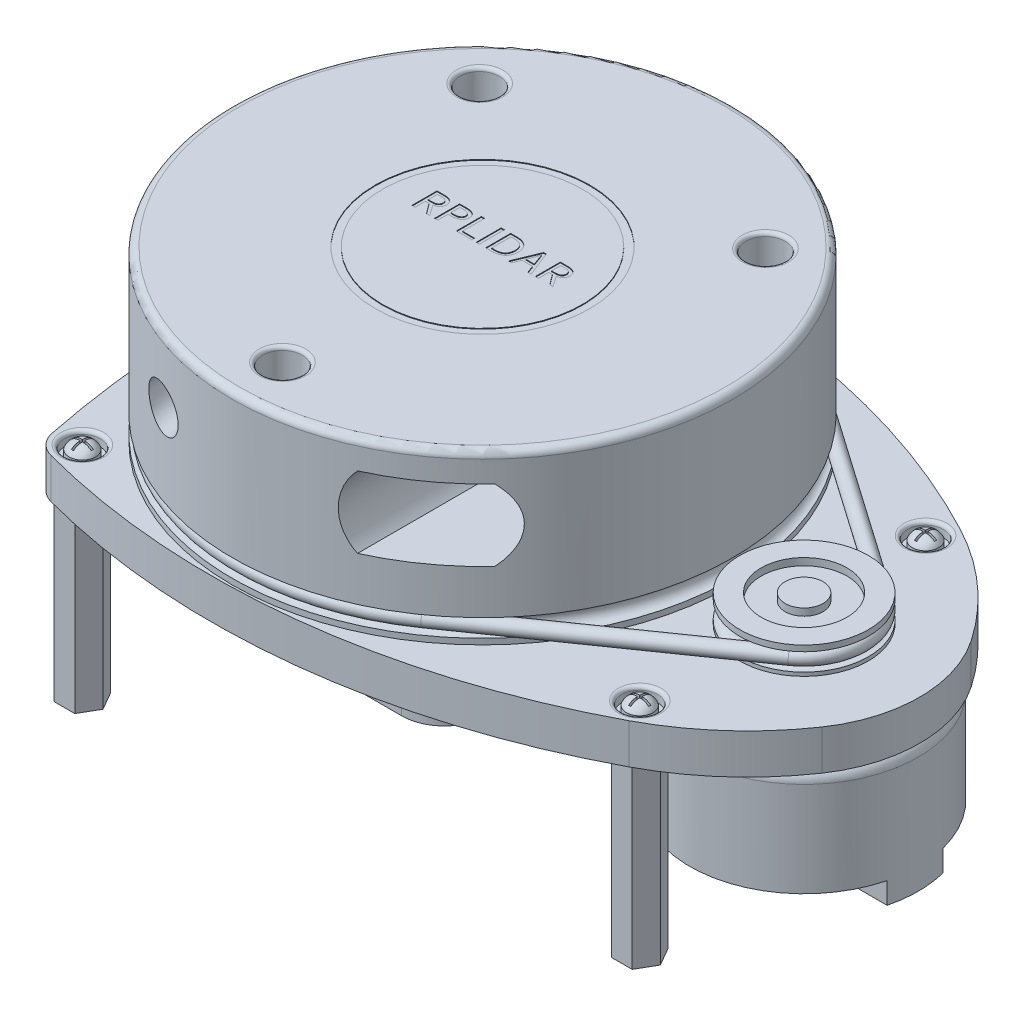
from build123d import *

# Parameters (mm, degrees)
SKETCH1_R                   = 35
PUCK_DEPTH                  = 23.5
FILLET1_R                   = 1
CUT_SENSOR_TUNNEL_DEPTH     = 55.792791624
BOSS_BOARD_START            = -0.5
BOSS_BOARD_DEPTH            = 5.6
HEX_STANDOFFS_DEPTH         = 25
SKETCH23_R                  = 2.5
SCREW_SEATS_DEPTH           = 1.5
FILLET_SCREW_SEATS_R        = 0.5
CUT_EXTRUDE5_START          = -0.5
CUT_EXTRUDE5_DEPTH          = 2
SKETCH6_R                   = 16
MOTOR_BODY_DEPTH            = 15
SKETCH9_R                   = 30
MOULD_BOTTOM_DISC_DEPTH     = 3.3
SKETCH10_W                  = 46
SKETCH10_H                  = 57
BOSS_CIRCUIT_DEPTH          = 1.1
FILLET_CIRCUIT_BOARD_R      = 6
SWEEP_BAND_PROFILE_R        = 1
FILLET3_R                   = 1.75
SKETCH18_R                  = 2.75
TOP_PUCK_HOLES_DEPTH        = 8
FILLET_PUCK_HOLES_R         = 0.5
SKETCH19_R                  = 15
SKETCH19_R_2                = 13.98
TOP_RING_AESTHETIC_DEPTH    = 0.1
SKETCH28_W                  = 0.443661972
SKETCH28_H                  = 3.5
RPLIDAR_TEXT_DEPTH          = 0.1
MOTOR_PLASTIC_FEATURE_DEPTH = 3
SKETCH31_R                  = 3.5
CUT_OPTICS_DEPTH            = 78.034465357
CUT_OPTICS_TAPER            = 1
SKETCH37_R                  = 1.25
DRILL_STANDOFFS_DEPTH       = 10


with BuildPart() as part:
    # Sketch1 → puck (new body)
    with BuildSketch(Plane(origin=(0, 0, 0), x_dir=(1, 0, 0), z_dir=(0, 1, 0))):
        with Locations(Location((0, 0, 0), (0, 0, 270))):
            Circle(SKETCH1_R)
    extrude(amount=PUCK_DEPTH)

    # Fillet1
    fillet1_edges = [part.edges().sort_by_distance(p)[0] for p in [
        (0, 23.5, -35),
    ]]
    fillet(fillet1_edges, radius=FILLET1_R)

    # Sketch2 → groove (revolve, cut)
    with BuildSketch(Plane.XY, mode=Mode.PRIVATE) as groove_sk:
        with BuildLine():
            Line((-35, 3.3), (-35, 0.8))
            ThreePointArc((-35, 0.8), (-33.75, 2.05), (-35, 3.3))
        make_face()
    revolve(groove_sk.sketch.rotate(Axis((0, 0, 0), (0, 1, 0)), 270), axis=Axis((0, 0, 0), (0, 1, 0)), mode=Mode.SUBTRACT)

    # Sketch3 → cut_sensor_tunnel (cut, through all)
    with BuildSketch(Plane.XY):
        with BuildLine():
            Line((14.409830056, 19.5), (25.590169944, 19.5))
            ThreePointArc((25.590169944, 19.5), (27.5, 14.5), (25.590169944, 9.5))
            Line((25.590169944, 9.5), (14.409830056, 9.5))
            ThreePointArc((14.409830056, 9.5), (12.5, 14.5), (14.409830056, 19.5))
        make_face()
    extrude(amount=CUT_SENSOR_TUNNEL_DEPTH, mode=Mode.SUBTRACT)



with BuildPart() as body_2:
    # Sketch4 → boss_board (new body)
    with BuildSketch(Plane(origin=(0, 0, 0), x_dir=(1, 0, 0), z_dir=(0, 1, 0)).offset(BOSS_BOARD_START)):
        with BuildLine():
            ThreePointArc((-28.9265577, 31.478719711), (8.165815302, 34.200883889), (43.687550184, 23.179964524))
            ThreePointArc((43.687550184, 23.179964524), (51.581142549, 17.68138932), (57.933651773, 10.457210733))
            ThreePointArc((57.933651773, 10.457210733), (61.172696898, 0), (57.933651773, -10.457210733))
            ThreePointArc((57.933651773, -10.457210733), (51.581142549, -17.68138932), (43.687550184, -23.179964524))
            ThreePointArc((43.687550184, -23.179964524), (8.165815302, -34.200883889), (-28.9265577, -31.478719711))
            ThreePointArc((-28.9265577, -31.478719711), (-30.621991293, -30.466812044), (-31.528712871, -28.712871287))
            ThreePointArc((-31.528712871, -28.712871287), (-34.4, 0), (-31.528712871, 28.712871287))
            ThreePointArc((-31.528712871, 28.712871287), (-30.621991293, 30.466812044), (-28.9265577, 31.478719711))
        make_face()
    extrude(amount=-BOSS_BOARD_DEPTH)

    # Sketch5 → hex_standoffs (add)
    with BuildSketch(Plane.XZ.offset(6.1)):
        Polygon((-26.556624327, 30.5), (-29.443375673, 30.5), (-30.886751346, 28), (-29.443375673, 25.5), (-26.556624327, 25.5), (-25.113248654, 28), align=None)
        Polygon((-26.556624327, -25.5), (-29.443375673, -25.5), (-30.886751346, -28), (-29.443375673, -30.5), (-26.556624327, -30.5), (-25.113248654, -28), align=None)
        Polygon((43.443375673, 22.5), (40.556624327, 22.5), (39.113248654, 20), (40.556624327, 17.5), (43.443375673, 17.5), (44.886751346, 20), align=None)
        Polygon((43.443375673, -17.5), (40.556624327, -17.5), (39.113248654, -20), (40.556624327, -22.5), (43.443375673, -22.5), (44.886751346, -20), align=None)
    extrude(amount=HEX_STANDOFFS_DEPTH)

    # Sketch23 → screw_seats (cut)
    with BuildSketch(Plane(origin=(0, -0.5, 0), x_dir=(1, 0, 0), z_dir=(0, 1, 0))):
        with Locations(Location((-28, 28, 0), (0, 0, 270))):
            Circle(SKETCH23_R)
        with Locations(Location((42, 20, 0), (0, 0, 270))):
            Circle(SKETCH23_R)
        with Locations(Location((42, -20, 0), (0, 0, 270))):
            Circle(SKETCH23_R)
        with Locations(Location((-28, -28, 0), (0, 0, 270))):
            Circle(SKETCH23_R)
    extrude(amount=-SCREW_SEATS_DEPTH, mode=Mode.SUBTRACT)

    # fillet_screw_seats
    fillet_screw_seats_edges = [body_2.edges().sort_by_distance(p)[0] for p in [
        (42, -0.5, 17.5),
        (-28, -0.5, 25.5),
        (-28, -0.5, -30.5),
        (42, -0.5, -22.5),
    ]]
    fillet(fillet_screw_seats_edges, radius=FILLET_SCREW_SEATS_R)

    # Sketch24 → revolve_screw_head (revolve)
    with BuildSketch(Plane.YZ.offset(-28), mode=Mode.PRIVATE) as revolve_screw_head_sk:
        with BuildLine():
            Line((-2, -28), (-2, -26.15))
            Line((-2, -26.15), (-1.041127656, -26.15))
            ThreePointArc((-1.041127656, -26.15), (-0.28319623, -26.795543768), (0, -27.75))
            Line((0, -27.75), (-1, -27.75))
            Line((-1, -27.75), (-1, -28))
            Line((-1, -28), (-2, -28))
        make_face()
    revolve_screw_head = revolve(revolve_screw_head_sk.sketch.rotate(Axis((-28, -2, -28), (0, 1, 0)), 180), axis=Axis((-28, -2, -28), (0, 1, 0)))

    # Sketch25 → Cut-Extrude5 (cut)
    with BuildSketch(Plane(origin=(0, -0.5, 0), x_dir=(1, 0, 0), z_dir=(0, 1, 0)).offset(CUT_EXTRUDE5_START)):
        Polygon((-27.85, 28.15), (-26.6, 28.15), (-26.6, 27.85), (-27.85, 27.85), (-27.85, 26.6), (-28.15, 26.6), (-28.15, 27.85), (-29.4, 27.85), (-29.4, 28.15), (-28.15, 28.15), (-28.15, 29.4), (-27.85, 29.4), align=None)
    cut_extrude5 = extrude(amount=CUT_EXTRUDE5_DEPTH, mode=Mode.SUBTRACT)

    # Sketch-Pattern1: revolve_screw_head, Cut-Extrude5 at 3 more places
    with Locations((70, 0, 8), (70, 0, 48), (0, 0, 56)):
        add(revolve_screw_head)
        add(cut_extrude5, mode=Mode.SUBTRACT)

    # Sketch9 → mould_bottom_disc (add)
    with BuildSketch(Plane.XZ.offset(6.1)):
        with Locations(Location((0, 0, 0), (0, 0, 90))):
            Circle(SKETCH9_R)
    extrude(amount=MOULD_BOTTOM_DISC_DEPTH)

    # Sketch10 → boss_circuit (add)
    with BuildSketch(Plane.XZ.offset(9.4)):
        with Locations((0.172696898, 0)):
            Rectangle(SKETCH10_W, SKETCH10_H)
    extrude(amount=BOSS_CIRCUIT_DEPTH)

    # fillet_circuit_board
    fillet_circuit_board_edges = [body_2.edges().sort_by_distance(p)[0] for p in [
        (-22.827303102, -9.95, 28.5),
        (-22.827303102, -9.95, -28.5),
        (23.172696898, -9.95, -28.5),
        (23.172696898, -9.95, 28.5),
    ]]
    fillet(fillet_circuit_board_edges, radius=FILLET_CIRCUIT_BOARD_R)


with BuildPart() as body_3:
    # Sketch6 → motor_body (new body)
    with BuildSketch(Plane.XZ.offset(6.1)):
        with Locations(Location((45, 0, 0), (0, 0, 270))):
            Circle(SKETCH6_R)
    extrude(amount=MOTOR_BODY_DEPTH)

    # Fillet3
    fillet3_edges = [body_3.edges().sort_by_distance(p)[0] for p in [
        (45, -6.1, 16),
    ]]
    fillet(fillet3_edges, radius=FILLET3_R)


    add(body_2.part)  # motor_plastic_feature merges body 2
    # Sketch30 → motor_plastic_feature (add)
    with BuildSketch(Plane.XZ.offset(21.1)):
        with BuildLine():
            Line((29.482590422, 3.9), (60.517409578, 3.9))
            ThreePointArc((60.517409578, 3.9), (61, 0), (60.517409578, -3.9))
            Line((60.517409578, -3.9), (29.482590422, -3.9))
            ThreePointArc((29.482590422, -3.9), (29, 0), (29.482590422, 3.9))
        make_face()
    extrude(amount=MOTOR_PLASTIC_FEATURE_DEPTH)

    # Sketch37 → drill_standoffs (cut)
    with BuildSketch(Plane.XZ.offset(31.1)):
        with Locations(Location((-28, 28, 0), (0, 0, 270))):
            Circle(SKETCH37_R)
        with Locations(Location((42, 20, 0), (0, 0, 270))):
            Circle(SKETCH37_R)
        with Locations(Location((-28, -28, 0), (0, 0, 270))):
            Circle(SKETCH37_R)
        with Locations(Location((42, -20, 0), (0, 0, 270))):
            Circle(SKETCH37_R)
    extrude(amount=-DRILL_STANDOFFS_DEPTH, mode=Mode.SUBTRACT)


with BuildPart() as body_4:
    # Sketch8 → motor_pulley (revolve)
    with BuildSketch(Plane.XY, mode=Mode.PRIVATE) as motor_pulley_sk:
        with BuildLine():
            Line((45, 4.1), (47.65, 4.1))
            Line((47.65, 4.1), (47.65, 3.1))
            Line((47.65, 3.1), (51, 3.1))
            Line((51, 3.1), (51, 4.1))
            Line((51, 4.1), (54, 4.1))
            Line((54, 4.1), (54, 3.283896268))
            ThreePointArc((54, 3.283896268), (52.55, 2.05), (54, 0.816103732))
            Line((54, 0.816103732), (54, 0.3))
            Line((54, 0.3), (47, 0.3))
            Line((47, 0.3), (47, 0))
            Line((47, 0), (45, 0))
            Line((45, 0), (45, 4.1))
        make_face()
    revolve(motor_pulley_sk.sketch.rotate(Axis((45, 0, 0), (0, 1, 0)), 90), axis=Axis((45, 0, 0), (0, 1, 0)))


with BuildPart() as part_1:
    add(part.part)

    add(body_4.part)  # sweep_band merges body 4
    # sweep_band: sweep along a path in Sketch12
    with BuildLine(Plane(origin=(0, 2.05, 0), x_dir=(1, 0, 0), z_dir=(0, 1, 0))) as sweep_band_path:
        Line((19.3125, 27.678328052), (49.577777778, 6.560788872))
        ThreePointArc((49.577777778, 6.560788872), (53, 0), (49.577777778, -6.560788872))
        Line((49.577777778, -6.560788872), (19.3125, -27.678328052))
        ThreePointArc((19.3125, -27.678328052), (-33.75, 0), (19.3125, 27.678328052))
    # sweep_band profile (on start of the path) → sweep_band (sweep)
    with BuildSketch(Plane(origin=(19.3125, 2.05, -27.678328052), x_dir=(-0.5722222222222224, 0, 0.8200986089459373), z_dir=(0.8200986089459373, 0, 0.5722222222222224))):
        Circle(SWEEP_BAND_PROFILE_R)
    sweep(path=sweep_band_path.line)

    # Sketch18 → top_puck_holes (cut)
    with BuildSketch(Plane(origin=(0, 23.5, 0), x_dir=(1, 0, 0), z_dir=(0, 1, 0))):
        with Locations(Location((-20, 19.595917942, 0), (0, 0, 270))):
            Circle(SKETCH18_R)
        with Locations(Location((20, 19.595917942, 0), (0, 0, 270))):
            Circle(SKETCH18_R)
        with Locations(Location((0, -28, 0), (0, 0, 270))):
            Circle(SKETCH18_R)
    extrude(amount=-TOP_PUCK_HOLES_DEPTH, mode=Mode.SUBTRACT)

    # fillet_puck_holes
    fillet_puck_holes_edges = [part_1.edges().sort_by_distance(p)[0] for p in [
        (-20, 23.5, -22.345917942),
        (20, 23.5, -22.345917942),
        (0, 23.5, 25.25),
    ]]
    fillet(fillet_puck_holes_edges, radius=FILLET_PUCK_HOLES_R)

    # Sketch19 → top_ring_aesthetic (cut)
    with BuildSketch(Plane(origin=(0, 23.5, 0), x_dir=(1, 0, 0), z_dir=(0, 1, 0))):
        with Locations(Location((0, 0, 0), (0, 0, 270))):
            Circle(SKETCH19_R)
        with Locations(Location((0, 0, 0), (0, 0, 270))):
            Circle(SKETCH19_R_2, mode=Mode.SUBTRACT)
    extrude(amount=-TOP_RING_AESTHETIC_DEPTH, mode=Mode.SUBTRACT)

    # Sketch28 → RPLIDAR_text (cut)
    with BuildSketch(Plane(origin=(0, 23.5, 0), x_dir=(1, 0, 0), z_dir=(0, 1, 0))):
        with BuildLine():
            Line((-9.518699354, 1.527961963), (-9.518699354, 0.098384498))
            Line((-9.518699354, 0.098384498), (-9.962361326, 0.098384498))
            Line((-9.962361326, 0.098384498), (-9.962361326, 3.598384498))
            Line((-9.962361326, 3.598384498), (-9.047308509, 3.598384498))
            add(Edge.make_bspline(
                [(-9.047308509, 3.598384498), (-9.010074022, 3.598406733), (-8.938406607, 3.59844953), (-8.835454477, 3.594052816), (-8.741143505, 3.589187689), (-8.629287432, 3.578782879), (-8.500608101, 3.562788655), (-8.402690794, 3.538449911), (-8.355627171, 3.526751576)],
                knots=[0, 0, 0, 0, 0.960912573, 1.849525173, 2.659327608, 3.397884282, 4.749301861, 6, 6, 6, 6], degree=3))
            add(Edge.make_bspline(
                [(-8.355627171, 3.526751576), (-8.32571201, 3.518179413), (-8.267044364, 3.501368252), (-8.182896367, 3.46957633), (-8.103929603, 3.433197836), (-8.030296037, 3.392915875), (-7.962477578, 3.347539331), (-7.899900797, 3.298359484), (-7.842624014, 3.244247606), (-7.791107469, 3.185503936), (-7.744719705, 3.123478914), (-7.705062654, 3.05699123), (-7.671385612, 2.987122817), (-7.643138712, 2.913593713), (-7.622839657, 2.835966663), (-7.607231695, 2.754961093), (-7.597863344, 2.669943095), (-7.596737884, 2.61197871), (-7.596164142, 2.582429393)],
                knots=[0, 0, 0, 0, 1.134140113, 2.224201012, 3.275431843, 4.3018668, 5.280587031, 6.24687456, 7.200337623, 8.148687011, 9.092220061, 10.020068992, 10.966198502, 11.917131199, 12.886677412, 13.887177189, 14.922916719, 16, 16, 16, 16], degree=3))
            add(Edge.make_bspline(
                [(-7.596164142, 2.582429393), (-7.596708206, 2.547714782), (-7.597772295, 2.479819302), (-7.611806916, 2.380968231), (-7.631595192, 2.287193362), (-7.66253987, 2.199922672), (-7.699103041, 2.117905917), (-7.743742684, 2.041835659), (-7.794233427, 1.970683492), (-7.852662405, 1.905951816), (-7.916519288, 1.846214648), (-7.98752068, 1.793148169), (-8.063581708, 1.744207137), (-8.146449252, 1.702193788), (-8.234058967, 1.665367549), (-8.326527306, 1.633842921), (-8.423283666, 1.606327376), (-8.490301937, 1.593685972), (-8.52431115, 1.587270942)],
                knots=[0, 0, 0, 0, 1.112196239, 2.175254001, 3.195927694, 4.180088583, 5.138074931, 6.0714415, 7.003609092, 7.93070943, 8.862804307, 9.803008288, 10.769096889, 11.759573608, 12.777920408, 13.814147618, 14.890763399, 16, 16, 16, 16], degree=3))
            Line((-8.52431115, 1.587270942), (-8.52431115, 1.577257738))
            Line((-8.52431115, 1.577257738), (-7.497572593, 0.098384498))
            Line((-7.497572593, 0.098384498), (-7.941234565, 0.098384498))
            Line((-7.941234565, 0.098384498), (-9.008796185, 1.527961963))
            Line((-9.008796185, 1.527961963), (-9.518699354, 1.527961963))
        make_face()
        with BuildLine():
            Line((-9.518699354, 3.204018301), (-9.518699354, 1.92232816))
            Line((-9.518699354, 1.92232816), (-9.108157981, 1.92232816))
            add(Edge.make_bspline(
                [(-9.108157981, 1.92232816), (-9.077604943, 1.922498152), (-9.018543453, 1.92282676), (-8.933504421, 1.924700236), (-8.855482158, 1.929845279), (-8.762988651, 1.936185347), (-8.657718255, 1.950503729), (-8.57830983, 1.972114046), (-8.540486326, 1.982407386)],
                knots=[0, 0, 0, 0, 0.960008608, 1.855774188, 2.671979062, 3.416289568, 4.769337359, 6, 6, 6, 6], degree=3))
            add(Edge.make_bspline(
                [(-8.540486326, 1.982407386), (-8.505942387, 1.994557563), (-8.439057128, 2.01808319), (-8.34806215, 2.067850302), (-8.269714912, 2.127792201), (-8.203968624, 2.197998884), (-8.150750125, 2.279302119), (-8.115648535, 2.373286011), (-8.092041092, 2.477539389), (-8.090124387, 2.550960175), (-8.089121889, 2.589361611)],
                knots=[0, 0, 0, 0, 1.071897366, 2.075447597, 3.025191329, 3.951603983, 4.882559323, 5.852363215, 6.876716796, 8, 8, 8, 8], degree=3))
            add(Edge.make_bspline(
                [(-8.089121889, 2.589361611), (-8.090561573, 2.625176577), (-8.093324599, 2.693912299), (-8.115315241, 2.791166821), (-8.149790048, 2.877951336), (-8.199465913, 2.952805195), (-8.260469502, 3.017205528), (-8.331379953, 3.07260791), (-8.413259495, 3.117993728), (-8.473353824, 3.138682278), (-8.504284741, 3.149330801)],
                knots=[0, 0, 0, 0, 1.140384521, 2.188614501, 3.161159596, 4.10078681, 5.032829337, 5.977325578, 6.958917162, 8, 8, 8, 8], degree=3))
            add(Edge.make_bspline(
                [(-8.504284741, 3.149330801), (-8.53777504, 3.158218463), (-8.609899374, 3.177358833), (-8.706556395, 3.190130518), (-8.794367396, 3.196598844), (-8.870856519, 3.201671854), (-8.956153478, 3.203533834), (-9.015985239, 3.203851826), (-9.047308509, 3.204018301)],
                knots=[0, 0, 0, 0, 1.138118458, 2.451039163, 3.196085275, 4.033155993, 4.970312991, 6, 6, 6, 6], degree=3))
            Line((-9.047308509, 3.204018301), (-9.518699354, 3.204018301))
        make_face(mode=Mode.SUBTRACT)
        with BuildLine():
            Line((-6.363769776, 0.098384498), (-6.807431748, 0.098384498))
            Line((-6.807431748, 0.098384498), (-6.807431748, 3.598384498))
            Line((-6.807431748, 3.598384498), (-5.829988966, 3.598384498))
            add(Edge.make_bspline(
                [(-5.829988966, 3.598384498), (-5.759832174, 3.597462125), (-5.624599428, 3.595684177), (-5.430047049, 3.574869123), (-5.250224094, 3.543768793), (-5.138517514, 3.508439134), (-5.084390375, 3.491320238)],
                knots=[0, 0, 0, 0, 1.112150433, 2.14375761, 3.100562468, 4, 4, 4, 4], degree=3))
            add(Edge.make_bspline(
                [(-5.084390375, 3.491320238), (-5.058575824, 3.481646157), (-5.008119455, 3.462737479), (-4.936236519, 3.429197865), (-4.868812074, 3.393156308), (-4.80617398, 3.353036392), (-4.748500732, 3.308942945), (-4.694848787, 3.262176186), (-4.647159921, 3.210908936), (-4.603868963, 3.156866202), (-4.564937641, 3.099736403), (-4.53185605, 3.03875291), (-4.504449687, 2.974603437), (-4.48055705, 2.907686648), (-4.46358854, 2.837088369), (-4.45015261, 2.763600569), (-4.4423331, 2.686840027), (-4.441606148, 2.634566957), (-4.441234565, 2.607847526)],
                knots=[0, 0, 0, 0, 1.124580066, 2.198071484, 3.23409666, 4.24257832, 5.229550713, 6.194477642, 7.143228582, 8.082444094, 9.018146757, 9.960512637, 10.908395419, 11.862683863, 12.856251848, 13.867396781, 14.909917807, 16, 16, 16, 16], degree=3))
            add(Edge.make_bspline(
                [(-4.441234565, 2.607847526), (-4.442649408, 2.564650906), (-4.445401195, 2.480635961), (-4.464378031, 2.358270788), (-4.498690357, 2.244629703), (-4.545185874, 2.138767882), (-4.604016205, 2.041024195), (-4.67551126, 1.951665438), (-4.759678695, 1.871343048), (-4.854903669, 1.798636997), (-4.961595438, 1.734555355), (-5.079897866, 1.680479949), (-5.20795629, 1.631990759), (-5.347675873, 1.594320408), (-5.4971941, 1.564446554), (-5.656408494, 1.542846751), (-5.825182835, 1.530892617), (-5.940886225, 1.528955318), (-6.000213438, 1.527961963)],
                knots=[0, 0, 0, 0, 0.968750745, 1.884164556, 2.767711883, 3.623640015, 4.470924939, 5.318933496, 6.182267056, 7.073659988, 8.000931356, 8.966940187, 9.987281083, 11.06853522, 12.207958729, 13.405037836, 14.669426411, 16, 16, 16, 16], degree=3))
            add(Edge.make_bspline(
                [(-6.000213438, 1.527961963), (-6.059547033, 1.528658581), (-6.180888037, 1.530083211), (-6.301920193, 1.538874426), (-6.363769776, 1.543366893)],
                knots=[0, 0, 0, 0, 0.977964451, 2, 2, 2, 2], degree=3))
            Line((-6.363769776, 1.543366893), (-6.363769776, 0.098384498))
        make_face()
        with BuildLine():
            add(Edge.make_bspline(
                [(-6.363769776, 1.943124815), (-6.33502979, 1.939900299), (-6.276603836, 1.933345132), (-6.18826656, 1.926148828), (-6.100870788, 1.923763732), (-6.043346986, 1.922795084), (-6.015618368, 1.92232816)],
                knots=[0, 0, 0, 0, 0.994453465, 2.021639473, 3.046356417, 4, 4, 4, 4], degree=3))
            add(Edge.make_bspline(
                [(-6.015618368, 1.92232816), (-5.968621978, 1.922955195), (-5.878143099, 1.92416238), (-5.748006844, 1.932306738), (-5.628691642, 1.94694808), (-5.519862599, 1.96683273), (-5.420638296, 1.991552563), (-5.332023761, 2.023885628), (-5.251678173, 2.058306843), (-5.181712887, 2.100638569), (-5.120527211, 2.147473948), (-5.068242641, 2.199372214), (-5.025448095, 2.256316227), (-4.991075903, 2.317687061), (-4.965916191, 2.384060302), (-4.947195186, 2.45447369), (-4.93652378, 2.52947182), (-4.934980054, 2.580856402), (-4.934192312, 2.60707728)],
                knots=[0, 0, 0, 0, 1.553856939, 2.991532652, 4.308749893, 5.52587743, 6.647999125, 7.684421496, 8.642023654, 9.533004122, 10.380289066, 11.184640834, 11.960536732, 12.728168995, 13.50220512, 14.301118221, 15.133082931, 16, 16, 16, 16], degree=3))
            add(Edge.make_bspline(
                [(-4.934192312, 2.60707728), (-4.935344719, 2.638997031), (-4.937557527, 2.700288103), (-4.955224548, 2.787822562), (-4.985604993, 2.866175802), (-5.027704336, 2.935711812), (-5.08132944, 2.996667767), (-5.144745351, 3.049744411), (-5.218341055, 3.095433512), (-5.272720399, 3.117762376), (-5.300829635, 3.129304393)],
                knots=[0, 0, 0, 0, 1.117778909, 2.146315848, 3.111871591, 4.048326347, 4.979190795, 5.943236808, 6.93683817, 8, 8, 8, 8], degree=3))
            add(Edge.make_bspline(
                [(-5.300829635, 3.129304393), (-5.339832016, 3.142243548), (-5.421897676, 3.169469075), (-5.532315897, 3.185215759), (-5.628306414, 3.195441172), (-5.707971757, 3.200670212), (-5.793503784, 3.203788672), (-5.852579673, 3.203940019), (-5.883135973, 3.204018301)],
                knots=[0, 0, 0, 0, 1.251428429, 2.633154656, 3.389182658, 4.197833418, 5.067850789, 6, 6, 6, 6], degree=3))
            Line((-5.883135973, 3.204018301), (-6.363769776, 3.204018301))
            Line((-6.363769776, 3.204018301), (-6.363769776, 1.943124815))
        make_face(mode=Mode.SUBTRACT)
        Polygon((-3.307431748, 3.598384498), (-3.307431748, 0.492750695), (-1.609808509, 0.492750695), (-1.609808509, 0.098384498), (-3.75109372, 0.098384498), (-3.75109372, 3.598384498), align=None)
        with Locations((-0.768699354, 1.848384498)):
            Rectangle(SKETCH28_W, SKETCH28_H)
        with BuildLine():
            add(Edge.make_bspline(
                [(3.150314731, 1.863789428), (3.149443844, 1.81343591), (3.147729768, 1.714330345), (3.13364302, 1.567840472), (3.109742173, 1.426064449), (3.076696044, 1.288832021), (3.034765887, 1.157298039), (2.982646364, 1.032098058), (2.921286243, 0.913698592), (2.850119864, 0.801865378), (2.768680253, 0.698114115), (2.67935871, 0.599815976), (2.578432809, 0.511124042), (2.469872483, 0.428119532), (2.351486307, 0.353672902), (2.222768364, 0.289655411), (2.085550219, 0.231519198), (1.988833616, 0.202015897), (1.939487266, 0.186962843)],
                knots=[0, 0, 0, 0, 1.078960079, 2.123604343, 3.150299665, 4.15788564, 5.14625318, 6.105773375, 7.060644044, 8.000881039, 8.941922687, 9.884282479, 10.842950369, 11.816876698, 12.810727448, 13.834395753, 14.895074244, 16, 16, 16, 16], degree=3))
            add(Edge.make_bspline(
                [(1.939487266, 0.186962843), (1.879630349, 0.171991893), (1.755831702, 0.141028331), (1.559399033, 0.115028184), (1.347914106, 0.100701746), (1.201874485, 0.099176051), (1.126106984, 0.098384498)],
                knots=[0, 0, 0, 0, 0.901624692, 1.864778919, 2.892215929, 4, 4, 4, 4], degree=3))
            Line((1.126106984, 0.098384498), (0.340455576, 0.098384498))
            Line((0.340455576, 0.098384498), (0.340455576, 3.598384498))
            Line((0.340455576, 3.598384498), (1.133809449, 3.598384498))
            add(Edge.make_bspline(
                [(1.133809449, 3.598384498), (1.209587801, 3.597718191), (1.355666633, 3.596433743), (1.566989149, 3.580431552), (1.763605875, 3.556025832), (1.887344943, 3.524872875), (1.947189731, 3.509806153)],
                knots=[0, 0, 0, 0, 1.107853918, 2.135623218, 3.09831846, 4, 4, 4, 4], degree=3))
            add(Edge.make_bspline(
                [(1.947189731, 3.509806153), (1.996512154, 3.494691918), (2.093088117, 3.46509743), (2.230450728, 3.407918313), (2.359178447, 3.344668763), (2.477323604, 3.270921469), (2.585789033, 3.189732734), (2.686479047, 3.103116464), (2.77461477, 3.00664934), (2.854733267, 2.904742967), (2.924698099, 2.795709248), (2.986149585, 2.680564615), (3.036859258, 2.558132262), (3.078265377, 2.429524041), (3.110546691, 2.295347556), (3.133556524, 2.156096754), (3.14776804, 2.011716668), (3.149456655, 1.913631655), (3.150314731, 1.863789428)],
                knots=[0, 0, 0, 0, 1.119747129, 2.192525263, 3.227419251, 4.231648869, 5.211937959, 6.16820741, 7.111232784, 8.044847219, 8.980607305, 9.92100777, 10.875812919, 11.85449892, 12.852610337, 13.870158293, 14.917713832, 16, 16, 16, 16], degree=3))
        make_face()
        with BuildLine():
            add(Edge.make_bspline(
                [(2.706652759, 1.863789428), (2.70615446, 1.904635136), (2.705181334, 1.984402598), (2.694865878, 2.101199204), (2.678394012, 2.211946807), (2.654138553, 2.316590364), (2.624326276, 2.415620836), (2.5876464, 2.508851932), (2.543293793, 2.595879037), (2.492257243, 2.676897555), (2.435317254, 2.752411649), (2.372435204, 2.822241928), (2.303866087, 2.886476418), (2.228654323, 2.944100931), (2.148192107, 2.996864802), (2.061896496, 3.043719699), (1.969684872, 3.084940398), (1.905267683, 3.107193102), (1.872475822, 3.118520942)],
                knots=[0, 0, 0, 0, 1.203903872, 2.351100332, 3.453730805, 4.502185143, 5.515033583, 6.500355373, 7.451594309, 8.390343524, 9.319861882, 10.23637587, 11.157535359, 12.085634934, 13.0261829, 13.991531864, 14.977580239, 16, 16, 16, 16], degree=3))
            add(Edge.make_bspline(
                [(1.872475822, 3.118520942), (1.846098914, 3.12621812), (1.792155586, 3.141959593), (1.708415315, 3.161193071), (1.619896043, 3.175794294), (1.52675616, 3.185961727), (1.428432891, 3.194922585), (1.324344381, 3.199540202), (1.214210288, 3.204076486), (1.138693385, 3.204038041), (1.099918604, 3.204018301)],
                knots=[0, 0, 0, 0, 0.845083279, 1.728277009, 2.64102572, 3.603014072, 4.609768268, 5.677380585, 6.807431769, 8, 8, 8, 8], degree=3))
            Line((1.099918604, 3.204018301), (0.784117548, 3.204018301))
            Line((0.784117548, 3.204018301), (0.784117548, 0.492750695))
            Line((0.784117548, 0.492750695), (1.099918604, 0.492750695))
            add(Edge.make_bspline(
                [(1.099918604, 0.492750695), (1.138692446, 0.492741284), (1.214207521, 0.492722954), (1.32435454, 0.497117049), (1.428376802, 0.502229902), (1.526864648, 0.509483949), (1.619829108, 0.521296992), (1.708424566, 0.535493596), (1.792153419, 0.554828683), (1.846098202, 0.570557208), (1.872475822, 0.578248055)],
                knots=[0, 0, 0, 0, 1.192525158, 2.322535528, 3.390109286, 4.396176414, 5.359069667, 6.271785412, 7.154947244, 8, 8, 8, 8], degree=3))
            add(Edge.make_bspline(
                [(1.872475822, 0.578248055), (1.905295054, 0.589513062), (1.96986564, 0.611676535), (2.061890396, 0.653901528), (2.14840877, 0.701401076), (2.228959152, 0.75572101), (2.303595628, 0.815826345), (2.37303251, 0.88149798), (2.435028726, 0.954450949), (2.492527668, 1.032329726), (2.543515195, 1.116532028), (2.587280139, 1.20688291), (2.624381401, 1.302721063), (2.65412504, 1.404084377), (2.678305021, 1.510783019), (2.694876588, 1.623302249), (2.705176048, 1.741639029), (2.706152762, 1.822430749), (2.706652759, 1.863789428)],
                knots=[0, 0, 0, 0, 1.006667003, 1.98057894, 2.934641552, 3.868938456, 4.796583139, 5.713780668, 6.638546881, 7.571683814, 8.52134086, 9.491281069, 10.482238571, 11.500889964, 12.554993275, 13.655371902, 14.799744318, 16, 16, 16, 16], degree=3))
        make_face(mode=Mode.SUBTRACT)
        Polygon((3.533127231, 0.098384498), (4.974258393, 3.598384498), (5.319328815, 3.598384498), (6.716555928, 0.098384498), (6.255948534, 0.098384498), (5.876217019, 1.133595766), (4.385019836, 1.133595766), (3.9883429, 0.098384498), align=None)
        with BuildLine():
            add(Edge.make_bspline(
                [(5.122145717, 3.056130977), (5.081045492, 2.94907454), (5.000827017, 2.740124245), (4.883899219, 2.434535785), (4.772820012, 2.144373935), (4.700578637, 1.956213449), (4.665389555, 1.864559674)],
                knots=[0, 0, 0, 0, 1.078349399, 2.104697591, 3.07679012, 4, 4, 4, 4], degree=3))
            Line((4.665389555, 1.864559674), (4.535988146, 1.527961963))
            Line((4.535988146, 1.527961963), (5.732180928, 1.527961963))
            Line((5.732180928, 1.527961963), (5.607400998, 1.866100167))
            add(Edge.make_bspline(
                [(5.607400998, 1.866100167), (5.57359919, 1.959075847), (5.504466408, 2.149233351), (5.396738013, 2.440212045), (5.286646829, 2.744435928), (5.210332616, 2.950908674), (5.171441491, 3.056130977)],
                knots=[0, 0, 0, 0, 0.936701532, 1.915778694, 2.937842541, 4, 4, 4, 4], degree=3))
            Line((5.171441491, 3.056130977), (5.122145717, 3.056130977))
        make_face(mode=Mode.SUBTRACT)
        with BuildLine():
            Line((7.734821773, 1.527961963), (7.734821773, 0.098384498))
            Line((7.734821773, 0.098384498), (7.291159801, 0.098384498))
            Line((7.291159801, 0.098384498), (7.291159801, 3.598384498))
            Line((7.291159801, 3.598384498), (8.206212618, 3.598384498))
            add(Edge.make_bspline(
                [(8.206212618, 3.598384498), (8.243447105, 3.598406733), (8.31511452, 3.59844953), (8.418066649, 3.594052816), (8.512377622, 3.589187689), (8.624233695, 3.578782879), (8.752913026, 3.562788655), (8.850830333, 3.538449911), (8.897893956, 3.526751576)],
                knots=[0, 0, 0, 0, 0.960912573, 1.849525173, 2.659327608, 3.397884282, 4.749301861, 6, 6, 6, 6], degree=3))
            add(Edge.make_bspline(
                [(8.897893956, 3.526751576), (8.927809117, 3.518179413), (8.986476763, 3.501368252), (9.07062476, 3.46957633), (9.149591524, 3.433197836), (9.22322509, 3.392915875), (9.291043549, 3.347539331), (9.353620329, 3.298359484), (9.410897113, 3.244247606), (9.462413658, 3.185503936), (9.508801421, 3.123478914), (9.548458472, 3.05699123), (9.582135515, 2.987122817), (9.610382414, 2.913593713), (9.63068147, 2.835966663), (9.646289431, 2.754961093), (9.655657782, 2.669943095), (9.656783243, 2.61197871), (9.657356984, 2.582429393)],
                knots=[0, 0, 0, 0, 1.134140113, 2.224201012, 3.275431843, 4.3018668, 5.280587031, 6.24687456, 7.200337623, 8.148687011, 9.092220061, 10.020068992, 10.966198502, 11.917131199, 12.886677412, 13.887177189, 14.922916719, 16, 16, 16, 16], degree=3))
            add(Edge.make_bspline(
                [(9.657356984, 2.582429393), (9.656812921, 2.547714782), (9.655748831, 2.479819302), (9.641714211, 2.380968231), (9.621925935, 2.287193362), (9.590981257, 2.199922672), (9.554418086, 2.117905917), (9.509778442, 2.041835659), (9.459287699, 1.970683492), (9.400858722, 1.905951816), (9.337001839, 1.846214648), (9.266000447, 1.793148169), (9.189939419, 1.744207137), (9.107071875, 1.702193788), (9.01946216, 1.665367549), (8.92699382, 1.633842921), (8.830237461, 1.606327376), (8.76321919, 1.593685972), (8.729209977, 1.587270942)],
                knots=[0, 0, 0, 0, 1.112196239, 2.175254001, 3.195927694, 4.180088583, 5.138074931, 6.0714415, 7.003609092, 7.93070943, 8.862804307, 9.803008288, 10.769096889, 11.759573608, 12.777920408, 13.814147618, 14.890763399, 16, 16, 16, 16], degree=3))
            Line((8.729209977, 1.587270942), (8.729209977, 1.577257738))
            Line((8.729209977, 1.577257738), (9.755948534, 0.098384498))
            Line((9.755948534, 0.098384498), (9.312286562, 0.098384498))
            Line((9.312286562, 0.098384498), (8.244724942, 1.527961963))
            Line((8.244724942, 1.527961963), (7.734821773, 1.527961963))
        make_face()
        with BuildLine():
            Line((7.734821773, 3.204018301), (7.734821773, 1.92232816))
            Line((7.734821773, 1.92232816), (8.145363146, 1.92232816))
            add(Edge.make_bspline(
                [(8.145363146, 1.92232816), (8.175916184, 1.922498152), (8.234977674, 1.92282676), (8.320016705, 1.924700236), (8.398038969, 1.929845279), (8.490532476, 1.936185347), (8.595802872, 1.950503729), (8.675211297, 1.972114046), (8.713034801, 1.982407386)],
                knots=[0, 0, 0, 0, 0.960008608, 1.855774188, 2.671979062, 3.416289568, 4.769337359, 6, 6, 6, 6], degree=3))
            add(Edge.make_bspline(
                [(8.713034801, 1.982407386), (8.747578739, 1.994557563), (8.814463999, 2.01808319), (8.905458977, 2.067850302), (8.983806215, 2.127792201), (9.049552502, 2.197998884), (9.102771002, 2.279302119), (9.137872591, 2.373286011), (9.161480034, 2.477539389), (9.163396739, 2.550960175), (9.164399238, 2.589361611)],
                knots=[0, 0, 0, 0, 1.071897366, 2.075447597, 3.025191329, 3.951603983, 4.882559323, 5.852363215, 6.876716796, 8, 8, 8, 8], degree=3))
            add(Edge.make_bspline(
                [(9.164399238, 2.589361611), (9.162959554, 2.625176577), (9.160196528, 2.693912299), (9.138205885, 2.791166821), (9.103731079, 2.877951336), (9.054055214, 2.952805195), (8.993051625, 3.017205528), (8.922141174, 3.07260791), (8.840261631, 3.117993728), (8.780167303, 3.138682278), (8.749236386, 3.149330801)],
                knots=[0, 0, 0, 0, 1.140384521, 2.188614501, 3.161159596, 4.10078681, 5.032829337, 5.977325578, 6.958917162, 8, 8, 8, 8], degree=3))
            add(Edge.make_bspline(
                [(8.749236386, 3.149330801), (8.715746086, 3.158218463), (8.643621753, 3.177358833), (8.546964732, 3.190130518), (8.459153731, 3.196598844), (8.382664607, 3.201671854), (8.297367648, 3.203533834), (8.237535888, 3.203851826), (8.206212618, 3.204018301)],
                knots=[0, 0, 0, 0, 1.138118458, 2.451039163, 3.196085275, 4.033155993, 4.970312991, 6, 6, 6, 6], degree=3))
            Line((8.206212618, 3.204018301), (7.734821773, 3.204018301))
        make_face(mode=Mode.SUBTRACT)
    extrude(amount=-RPLIDAR_TEXT_DEPTH, mode=Mode.SUBTRACT)

    # Sketch31 → cut_optics (cut, through all)
    with BuildSketch(Plane(origin=(0, 0, 0), x_dir=(0, -1, 0), z_dir=(0.17364817766693072, 0, 0.984807753012208))):
        with Locations((-14.5, -17.390175692)):
            Circle(SKETCH31_R)
    extrude(amount=CUT_OPTICS_DEPTH, taper=CUT_OPTICS_TAPER, mode=Mode.SUBTRACT)


solid = Compound([body_3.part, part_1.part])
